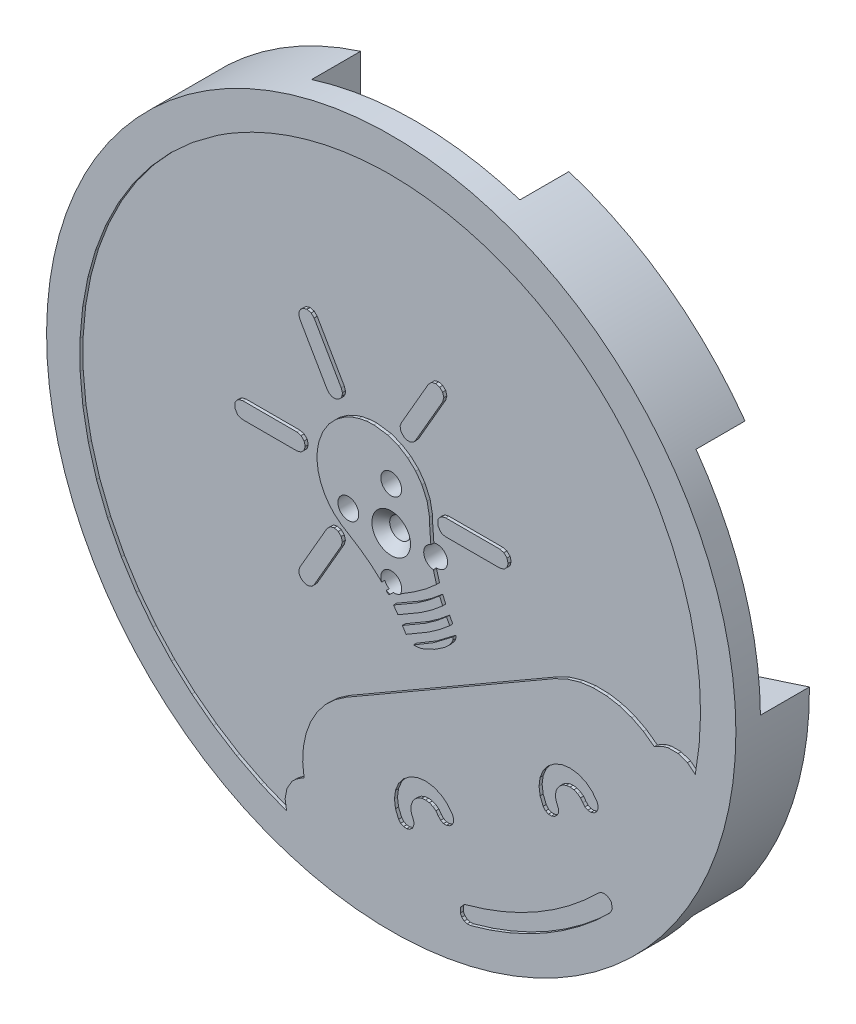
from build123d import *

# Parameters (mm, degrees)
SKETCH2_R                                       = 56.25
BOSS_EXTRUDE1_DEPTH                             = 12
SKETCH4_R                                       = 10
CUT_EXTRUDE2_DEPTH                              = 2
M3_CLEARANCE_HOLE1_D                            = 3.4
M3_CLEARANCE_HOLE1_DEPTH                        = 10
M3_CLEARANCE_HOLE1_TIP                          = 1.021463052
CSK_FOR_M3_FLAT_HEAD_MACHINE_SCREW2_D           = 3.4
CSK_FOR_M3_FLAT_HEAD_MACHINE_SCREW2_DEPTH       = 10
CSK_FOR_M3_FLAT_HEAD_MACHINE_SCREW2_CSINK_D     = 6.3
CSK_FOR_M3_FLAT_HEAD_MACHINE_SCREW2_CSINK_ANGLE = 90
CSK_FOR_M3_FLAT_HEAD_MACHINE_SCREW2_TIP         = 1.021463052
CUT_EXTRUDE3_DEPTH                              = 8
CIRPATTERN1_COUNT                               = 5
SKETCH11_R                                      = 5.25
CUT_EXTRUDE4_DEPTH                              = 2.5
CUT_EXTRUDE6_DEPTH                              = 0.5


with BuildPart() as part:
    # Sketch2 → Boss-Extrude1 (new body)
    with BuildSketch(Plane.XY):
        Circle(SKETCH2_R)
    extrude(amount=BOSS_EXTRUDE1_DEPTH)

    # Sketch4 → Cut-Extrude2 (cut)
    with BuildSketch(Plane(origin=(0, 0, 0), x_dir=(-1, 0, 0), z_dir=(0, 0, -1))):
        Circle(SKETCH4_R)
    extrude(amount=-CUT_EXTRUDE2_DEPTH, mode=Mode.SUBTRACT)

    # M3 Clearance Hole1
    with Locations(Plane(origin=(0, 0, 2), x_dir=(-1, 0, 0), z_dir=(0, 0, -1))):
        with Locations((7, 0), (0, 7), (-7, 0), (0, -7)):
            Hole(M3_CLEARANCE_HOLE1_D / 2, depth=M3_CLEARANCE_HOLE1_DEPTH)
            with Locations((0, 0, -(M3_CLEARANCE_HOLE1_DEPTH + M3_CLEARANCE_HOLE1_TIP / 2))):  # 118° drill point
                Cone(0, M3_CLEARANCE_HOLE1_D / 2, M3_CLEARANCE_HOLE1_TIP, mode=Mode.SUBTRACT)

    # CSK for M3 Flat Head Machine Screw2
    with Locations(Plane.XY.offset(12)):
        with Locations((0, 0)):
            CounterSinkHole(CSK_FOR_M3_FLAT_HEAD_MACHINE_SCREW2_D / 2, CSK_FOR_M3_FLAT_HEAD_MACHINE_SCREW2_CSINK_D / 2, depth=CSK_FOR_M3_FLAT_HEAD_MACHINE_SCREW2_DEPTH, counter_sink_angle=CSK_FOR_M3_FLAT_HEAD_MACHINE_SCREW2_CSINK_ANGLE)
            with Locations((0, 0, -(CSK_FOR_M3_FLAT_HEAD_MACHINE_SCREW2_DEPTH + CSK_FOR_M3_FLAT_HEAD_MACHINE_SCREW2_TIP / 2))):  # 118° drill point
                Cone(0, CSK_FOR_M3_FLAT_HEAD_MACHINE_SCREW2_D / 2, CSK_FOR_M3_FLAT_HEAD_MACHINE_SCREW2_TIP, mode=Mode.SUBTRACT)

    # Sketch3 → Cut-Extrude3 (cut)
    with BuildSketch(Plane(origin=(0, 0, 0), x_dir=(-1, 0, 0), z_dir=(0, 0, -1))):
        with BuildLine():
            Line((-17, 34.65), (-17, 53.619609286))
            ThreePointArc((-17, 53.619609286), (0, 56.25), (17, 53.619609286))
            Line((17, 53.619609286), (17, 34.65))
            ThreePointArc((17, 34.65), (0, 17.65), (-17, 34.65))
        make_face()
    cut_extrude3 = extrude(amount=-CUT_EXTRUDE3_DEPTH, mode=Mode.SUBTRACT)

    # CirPattern1: Cut-Extrude3 ×5 about axis
    cirpattern1_axis = Axis((0, 0, 0), (0, 0, 1))
    for i in range(1, CIRPATTERN1_COUNT):
        add(cut_extrude3.rotate(cirpattern1_axis, i * 360 / CIRPATTERN1_COUNT), mode=Mode.SUBTRACT)

    # Sketch11 → Cut-Extrude4 (cut)
    with BuildSketch(Plane(origin=(0, 0, 8), x_dir=(-1, 0, 0), z_dir=(0, 0, -1))):
        with Locations((0, 34.65)):
            Circle(SKETCH11_R)
    extrude(amount=-CUT_EXTRUDE4_DEPTH, mode=Mode.SUBTRACT)

    # Sketch12 → Cut-Extrude6 (cut)
    with BuildSketch(Plane.XY.offset(12)):
        Polygon((43.723461199, 25.299357978), (42.862286199, 26.735807978), (41.945412199, 28.154097978), (40.111573199, 30.715630978), (38.134769199, 33.143464978), (36.022658199, 35.433187978), (33.782896199, 37.580389978), (31.423141199, 39.580658978), (28.951050199, 41.429584978), (26.374282199, 43.122755978), (23.700492199, 44.655759978), (20.937339199, 46.024187978), (18.092480199, 47.223627978), (15.173572199, 48.249668978), (12.188273199, 49.097899978), (9.144240199, 49.763908978), (6.049131199, 50.243285978), (2.910602199, 50.531618978), (-0.263687801, 50.624497978), (-1.359327801, 50.610583978), (-4.530018801, 50.436169978), (-7.674349801, 50.064932978), (-10.783406801, 49.499376978), (-13.848277801, 48.742003978), (-16.860048801, 47.795318978), (-19.809805801, 46.661822978), (-22.688636801, 45.344020978), (-25.487627801, 43.844413978), (-25.507213801, 43.833096978), (-25.513874801, 43.829258978), (-26.568974801, 43.201636978), (-26.730230801, 43.102808978), (-27.561199801, 42.579766978), (-27.566928801, 42.576464978), (-28.015088801, 42.283345978), (-28.454917801, 41.991223978), (-32.415556801, 39.037269978), (-36.011022801, 35.772805978), (-39.234224801, 32.228485978), (-42.078071801, 28.434963978), (-44.535474801, 24.422892978), (-46.599340801, 20.222926978), (-48.262581801, 15.865718978), (-49.518104801, 11.381923978), (-50.358820801, 6.802193978), (-50.777638801, 2.157182978), (-50.767468801, -2.522455022), (-50.321218801, -7.206067022), (-49.431799801, -11.862998022), (-48.092119801, -16.462596022), (-46.295089801, -20.974207022), (-44.033617801, -25.367176022), (-41.609881801, -29.164592022), (-38.875449801, -32.711398022), (-35.850474801, -35.990843022), (-32.555109801, -38.986176022), (-29.009508801, -41.680647022), (-25.233823801, -44.057504022), (-21.248209801, -46.099998022), (-17.072817801, -47.791376022), (-17.319989801, -46.163829022), (-17.016264801, -44.576959022), (-16.198493801, -43.170813022), (-15.608356801, -42.579276022), (-14.903527801, -42.085436022), (-14.225387801, -41.694561022), (-14.448117801, -39.532021022), (-14.340495801, -37.381857022), (-13.912494801, -35.281382022), (-13.174084801, -33.267908022), (-12.135239801, -31.378746022), (-10.805930801, -29.651210022), (-9.196128801, -28.122611022), (-7.315807801, -26.830261022), (26.596892199, -7.252061022), (28.656207199, -6.269740022), (30.784744199, -5.639707022), (32.945242199, -5.351981022), (35.100438199, -5.396584022), (37.213073199, -5.763536022), (39.245885199, -6.442857022), (41.161611199, -7.424569022), (42.922992199, -8.698691022), (43.601891199, -8.308031022), (44.381276199, -7.944688022), (45.187870199, -7.729078022), (46.813011199, -7.722320022), (48.337975199, -8.250275022), (49.623421199, -9.275463022), (50.251013199, -4.817872022), (50.480416199, -0.348635022), (50.316017199, 4.106506978), (49.762207199, 8.521811978), (48.823374199, 12.871538978), (47.503908199, 17.129945978), (45.808197199, 21.271292978), (43.740631199, 25.269836978), align=None)
        Polygon((18.891861199, 5.946657978), (19.071533199, 5.250624978), (18.884073199, 4.599423978), (18.404677199, 4.120544978), (17.708541199, 3.941477978), (8.906121199, 3.941195978), (8.423778199, 4.016983978), (8.037522199, 4.234572978), (7.590738199, 4.948372978), (7.640696199, 5.789029978), (7.875369199, 6.165189978), (8.262325199, 6.462975978), (8.886476199, 6.617743978), (8.906485199, 6.617178978), (17.706925199, 6.617743978), (18.391093199, 6.444256978), align=None, mode=Mode.SUBTRACT)
        Polygon((8.384066199, 24.134679978), (8.576710199, 23.446719978), (8.387927199, 22.757627978), (3.987357199, 15.135237978), (3.597633199, 14.665372978), (3.121730199, 14.443854978), (2.617042199, 14.437529978), (2.140963199, 14.613245978), (1.750887199, 14.937849978), (1.504208199, 15.378187978), (1.458320199, 15.901107978), (1.670617199, 16.473457978), (6.070707199, 24.095567978), (6.607050199, 24.622904978), (7.230701199, 24.781837978), (7.249046199, 24.780990978), (7.900786199, 24.605753978), align=None, mode=Mode.SUBTRACT)
        Polygon((5.000081199, 9.375150978), (5.850797199, 7.463807978), (6.249571199, 5.389737978), (6.265855199, 4.283367978), (6.577471199, -0.044406022), (6.911352199, -1.858571022), (7.381665199, -3.547262022), (5.689823199, -5.013802022), (3.650535199, -6.472260022), (1.513868199, -7.797723022), (-0.470114801, -8.865282022), (-1.770931801, -7.451855022), (-3.263086801, -6.123730022), (-5.031418801, -4.812093022), (-7.160764801, -3.448132022), (-8.108988801, -2.881732022), (-9.208387801, -1.997921022), (-10.151440801, -0.965659022), (-10.925171801, 0.192627978), (-11.516605801, 1.454513978), (-11.912766801, 2.797572978), (-12.100679801, 4.199378978), (-12.067368801, 5.637505978), (-11.799858801, 7.089527978), (-11.139502801, 8.829601978), (-10.173968801, 10.357967978), (-8.950054801, 11.647315978), (-7.514558801, 12.670337978), (-6.427689801, 13.205966978), (-5.274997801, 13.595999978), (-4.071640801, 13.831703978), (-2.832778801, 13.904347978), (-0.539738801, 13.590550978), (1.182022199, 12.939883978), (2.696139199, 11.991059978), (3.977271199, 10.788130978), align=None, mode=Mode.SUBTRACT)
        Polygon((7.889381199, -4.917242022), (8.395024199, -6.063132022), (6.781486199, -7.414278022), (4.899424199, -8.746247022), (1.094884199, -10.972912022), (0.373801199, -9.948862022), (4.252210199, -7.705099022), (6.179345199, -6.342944022), align=None, mode=Mode.SUBTRACT)
        Polygon((9.012791199, -7.316142022), (9.543738199, -8.295306022), (7.956169199, -9.610904022), (6.121214199, -10.905201022), (2.413428199, -13.080306022), (1.823609199, -12.116038022), (5.524136199, -9.963794022), (7.362161199, -8.670749022), align=None, mode=Mode.SUBTRACT)
        Polygon((10.091741199, -9.603872022), (10.051374199, -10.086293022), (9.860443199, -10.539387022), (9.332898199, -11.221127022), (8.717833199, -11.775481022), (7.252363199, -12.761217022), (7.124432199, -12.835077022), (5.538033199, -13.611342022), (4.750413199, -13.866833022), (3.896232199, -13.982827022), (3.637519199, -13.967982022), (6.973677199, -11.970885022), align=None, mode=Mode.SUBTRACT)
        Polygon((-12.587925801, 24.132621978), (-12.566715802, 24.095800979), (-8.166085801, 16.473690978), (-7.963309801, 15.905040978), (-8.013034801, 15.386528978), (-8.259374801, 14.950421978), (-8.646438801, 14.628988978), (-9.118339801, 14.454496978), (-9.619188801, 14.459212978), (-10.093096801, 14.675404978), (-10.484175801, 15.135340978), (-14.884795801, 22.757450978), (-15.061350801, 23.258571978), (-15.033095801, 23.770787978), (-14.814930801, 24.235085978), (-14.421759801, 24.592450978), (-13.787025801, 24.780698978), (-13.721115801, 24.781263978), (-13.070058801, 24.604475978), align=None, mode=Mode.SUBTRACT)
        Polygon((-14.219454801, 5.940123978), (-14.042997801, 5.246106978), (-14.230999801, 4.597437978), (-14.708885801, 4.120202978), (-15.402098801, 3.940457978), (-24.203568801, 3.940649978), (-24.686732801, 4.015917978), (-25.073591801, 4.233461978), (-25.520846801, 4.948013978), (-25.470242801, 5.789586978), (-25.234775801, 6.165905978), (-24.846684801, 6.463459978), (-24.222460801, 6.616996978), (-24.203184801, 6.616714978), (-15.400764801, 6.616996978), (-14.717569801, 6.440076978), align=None, mode=Mode.SUBTRACT)
        Polygon((-8.170068801, -4.538742022), (-7.977775801, -5.226495022), (-8.166456801, -5.915292022), (-12.566076801, -13.537132022), (-12.959617801, -13.975692022), (-13.428920801, -14.180400022), (-13.921293801, -14.181645022), (-14.384045801, -14.009815022), (-14.764484801, -13.695299022), (-15.009918801, -13.268488022), (-15.067655801, -12.759769022), (-14.885006801, -12.199532022), (-10.484436801, -4.577142022), (-9.947616801, -4.049531022), (-9.323338801, -3.892782022), (-9.305360801, -3.891935022), (-8.653708801, -4.067534022), align=None, mode=Mode.SUBTRACT)
        Polygon((33.579361199, -21.123242022), (32.766486199, -20.066696022), (31.724150199, -19.269287022), (30.512280199, -18.765518022), (29.190801199, -18.589892022), (27.869140199, -18.765545022), (26.656896199, -19.269445022), (25.614190199, -20.066998022), (24.801141199, -21.123612022), (24.292617199, -22.355967022), (24.123288199, -23.657596022), (24.293027199, -24.959222022), (24.801705199, -26.191572022), (25.192782199, -26.651508022), (25.666690199, -26.867700022), (26.167539199, -26.872416022), (26.639441199, -26.697924022), (27.026506199, -26.376491022), (27.272847199, -25.940384022), (27.322573199, -25.421872022), (27.119795199, -24.853222022), (26.878829199, -24.271019022), (26.798350199, -23.657726022), (26.878452199, -23.044436022), (27.119231199, -22.462242022), (27.503091199, -21.962474022), (27.994288199, -21.586165022), (28.565779199, -21.348930022), (29.190521199, -21.266382022), (29.815194199, -21.348897022), (30.386543199, -21.586067022), (30.877598199, -21.962313022), (31.261391199, -22.462052022), (31.615354199, -22.872019022), (32.083964199, -23.102570022), (32.605050199, -23.137027022), (33.116441199, -22.958709022), (33.509782199, -22.601197022), (33.727977199, -22.136751022), (33.756095199, -21.624414022), align=None)
        Polygon((35.913642199, -34.208551022), (35.701869199, -33.934293022), (35.258154199, -33.640231022), (34.753633199, -33.542528022), (34.249288199, -33.641132022), (33.806099199, -33.935986022), (31.499014199, -36.099148022), (29.062643199, -38.099441022), (26.505803199, -39.931782022), (23.837308199, -41.591088022), (21.065974199, -43.072274022), (18.200618199, -44.370259022), (15.250054199, -45.479957022), (12.223099199, -46.396286022), (11.889936199, -46.535808022), (11.328824199, -47.182684022), (11.273766199, -48.037238022), (11.510157199, -48.514182022), (11.897635199, -48.851743022), (12.383417199, -49.019386022), (12.914716199, -48.986571022), (16.110675199, -48.019061022), (19.226043199, -46.847350022), (22.251494199, -45.476817022), (25.177698199, -43.912840022), (27.995331199, -42.160799022), (30.695063199, -40.226071022), (33.267567199, -38.114036022), (35.703516199, -35.830071022), (36.084418199, -35.055056022), align=None)
        Polygon((9.982267199, -34.747662022), (9.169224199, -33.690986022), (8.126532199, -32.893345022), (6.914307199, -32.389347022), (5.592671199, -32.213622022), (4.271201199, -32.389262022), (3.059377199, -32.893139022), (2.017093199, -33.690672022), (1.204241199, -34.747282022), (0.695574199, -35.979723022), (0.525940199, -37.281541022), (0.695390199, -38.583356022), (1.203973199, -39.815792022), (1.549674199, -40.218891022), (2.007098199, -40.450281022), (2.517873199, -40.493382022), (3.023623199, -40.331612022), (3.434022199, -39.978168022), (3.665136199, -39.509843022), (3.700221199, -38.988793022), (3.522535199, -38.477172022), (3.281650199, -37.894931022), (3.201340199, -37.281543022), (3.281615199, -36.668156022), (3.522487199, -36.085912022), (3.906196199, -35.586230022), (4.397070199, -35.210110022), (4.968237199, -34.973064022), (5.592827199, -34.890602022), (6.217539199, -34.972991022), (6.788963199, -35.209889022), (7.280086199, -35.585873022), (7.663897199, -36.085522022), (8.054456199, -36.548413022), (8.528877199, -36.766261022), (9.030833199, -36.771570022), (9.503999199, -36.596844022), (9.892051199, -36.274587022), (10.138663199, -35.837302022), (10.187510199, -35.317492022), align=None)
    extrude(amount=-CUT_EXTRUDE6_DEPTH, mode=Mode.SUBTRACT)


solid = part.part
